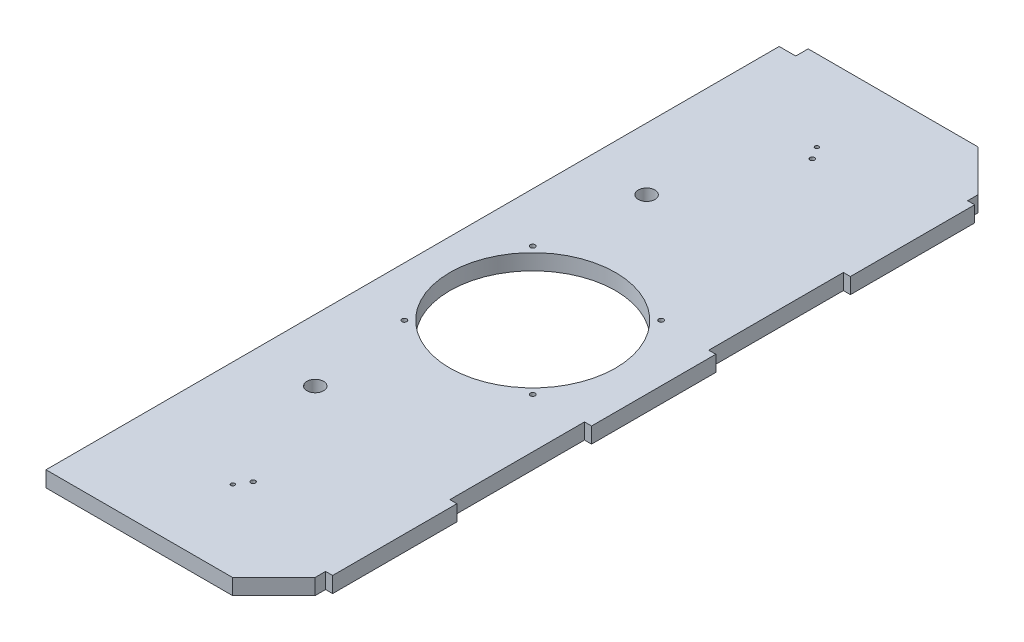
from build123d import *

# Parameters (mm, degrees)
SKETCH1_W                    = 139.7
SKETCH1_H                    = 457.2
SKETCH1_R                    = 50.8
SKETCH1_R_2                  = 5.08
BOSS_EXTRUDE1_DEPTH          = 9.652
SKETCH4_W                    = 10.16
SKETCH4_H                    = 7.62
CUT_EXTRUDE1_DEPTH           = 10.652
CHAMFER1_SIZE                = 25.4
SKETCH5_W                    = 76.2
SKETCH5_H                    = 9.652
BOSS_EXTRUDE2_DEPTH          = 4.318
F_3_0_3_DIAMETER_HOLE1_D     = 3
F_3_0_3_DIAMETER_HOLE1_DEPTH = 9.652
SKETCH10_R                   = 1.167867484
SKETCH10_R_2                 = 1.416247351
CUT_EXTRUDE2_DEPTH           = 9.652


with BuildPart() as part:
    # Sketch1 → Boss-Extrude1 (new body)
    with BuildSketch(Plane(origin=(0, 0, 0), x_dir=(1, 0, 0), z_dir=(0, 1, 0))):
        with Locations((69.85, 228.6)):
            Rectangle(SKETCH1_W, SKETCH1_H)
        with Locations((69.85, 228.6)):
            Circle(SKETCH1_R, mode=Mode.SUBTRACT)
        with Locations((38.1, 127)):
            Circle(SKETCH1_R_2, mode=Mode.SUBTRACT)
        with Locations((38.1, 330.2)):
            Circle(SKETCH1_R_2, mode=Mode.SUBTRACT)
    extrude(amount=BOSS_EXTRUDE1_DEPTH)

    # Sketch4 → Cut-Extrude1 (cut, through all)
    with BuildSketch(Plane(origin=(0, 9.652, 0), x_dir=(1, 0, 0), z_dir=(0, 1, 0))):
        with Locations((5.08, 453.39)):
            Rectangle(SKETCH4_W, SKETCH4_H)
    extrude(amount=-CUT_EXTRUDE1_DEPTH, mode=Mode.SUBTRACT)

    # Chamfer1
    chamfer1_edges = [part.edges().sort_by_distance(p)[0] for p in [
        (139.7, 4.826, -457.2),
        (139.7, 4.826, 0),
    ]]
    chamfer(chamfer1_edges, length=CHAMFER1_SIZE)

    # Sketch5 → Boss-Extrude2 (add)
    with BuildSketch(Plane(origin=(139.7, 0, 0), x_dir=(0, 0, -1), z_dir=(1, 0, 0))):
        with Locations((69.85, 4.826)):
            Rectangle(SKETCH5_W, SKETCH5_H)
        with Locations((228.6, 4.826)):
            Rectangle(SKETCH5_W, SKETCH5_H)
        with Locations((387.35, 4.826)):
            Rectangle(SKETCH5_W, SKETCH5_H)
    extrude(amount=BOSS_EXTRUDE2_DEPTH)

    # Ø3.0 (3) Diameter Hole1
    with Locations(Plane(origin=(0, 9.652, 0), x_dir=(1, 0, 0), z_dir=(0, 1, 0))):
        with Locations((109.22, 189.23), (30.48, 189.23), (30.48, 267.97), (109.22, 267.97)):
            Hole(F_3_0_3_DIAMETER_HOLE1_D / 2, depth=F_3_0_3_DIAMETER_HOLE1_DEPTH)

    # Sketch10 → Cut-Extrude2 (cut)
    with BuildSketch(Plane(origin=(0, 9.652, 0), x_dir=(1, 0, 0), z_dir=(0, 1, 0))):
        with Locations((65.024, 49.53)):
            Circle(SKETCH10_R)
        with Locations((69.85, 57.15)):
            Circle(SKETCH10_R_2)
    cut_extrude2 = extrude(amount=-CUT_EXTRUDE2_DEPTH, mode=Mode.SUBTRACT)

    # Mirror1: Cut-Extrude2 across plane
    add(cut_extrude2.mirror(Plane.XY.offset(-228.6)), mode=Mode.SUBTRACT)


solid = part.part
